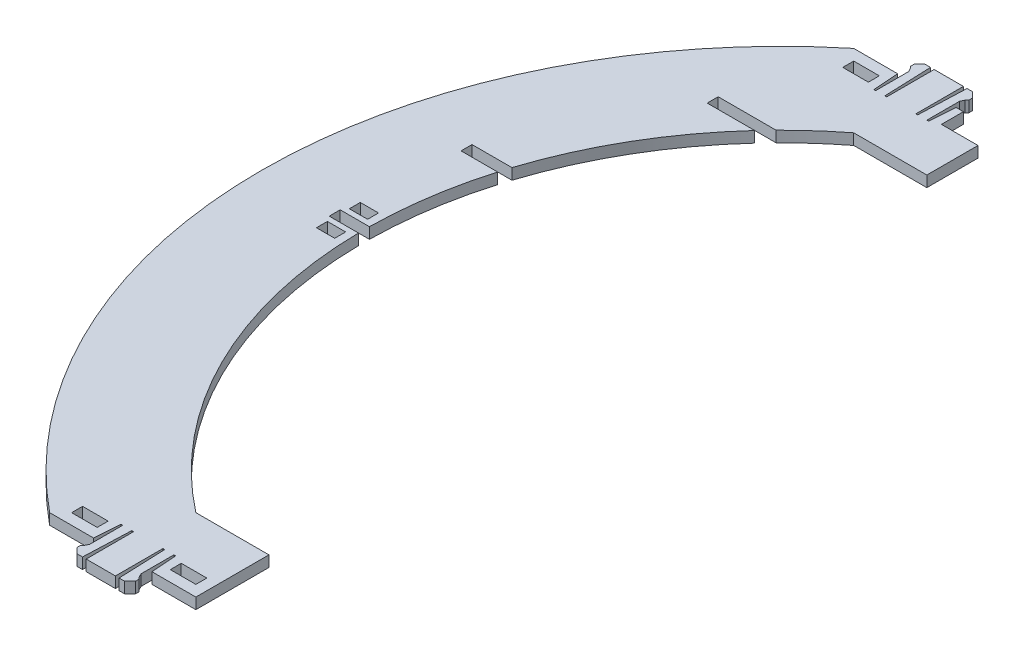
from build123d import *

# Parameters (mm, degrees)
BOSS_EXTRUDE2_DEPTH      = 3
SKETCH3_W                = 10
SKETCH3_H                = 6
SKETCH3_W_2              = 7
SKETCH3_H_2              = 3
CUT_EXTRUDE1_DEPTH       = 3
CUT_EXTRUDE3_DEPTH       = 1
CUT_EXTRUDE3_DEPTH_BACK  = 3
SKETCH10_W               = 5
SKETCH10_H               = 3
CUT_EXTRUDE4_DEPTH       = 10
CUT_EXTRUDE12_DEPTH      = 1
CUT_EXTRUDE12_DEPTH_BACK = 3
CUT_EXTRUDE13_DEPTH      = 1
CUT_EXTRUDE13_DEPTH_BACK = 3


with BuildPart() as part:
    # Sketch2 → Boss-Extrude2 (new body)
    with BuildSketch(Plane(origin=(0, 0, 0), x_dir=(1, 0, 0), z_dir=(0, 1, 0))):
        with BuildLine():
            Line((-70, 90), (-50, 90))
            Line((-50, 90), (-50, 110))
            Line((-50, 110), (-61.99554496, 110))
            Line((-61.99554496, 110), (-62.49554496, 102.997828908))
            Line((-62.49554496, 102.997828908), (-62.99554496, 102.997828908))
            Line((-62.99554496, 102.997828908), (-62.99554496, 111.997828908))
            Line((-62.99554496, 111.997828908), (-62.49554496, 112.997828908))
            Line((-62.49554496, 112.997828908), (-61.99554496, 113.497828908))
            Line((-61.99554496, 113.497828908), (-61.99554496, 114.497828908))
            Line((-61.99554496, 114.497828908), (-63.49554496, 115.997828908))
            Line((-63.49554496, 115.997828908), (-64.99554496, 115.997828908))
            Line((-64.99554496, 115.997828908), (-65.49554496, 102.997828908))
            Line((-65.49554496, 102.997828908), (-65.99554496, 102.997828908))
            Line((-65.99554496, 102.997828908), (-65.99554496, 115.997828908))
            Line((-65.99554496, 115.997828908), (-73.99554496, 115.997828908))
            Line((-73.99554496, 115.997828908), (-73.99554496, 102.997828908))
            Line((-73.99554496, 102.997828908), (-74.49554496, 102.997828908))
            Line((-74.49554496, 102.997828908), (-74.99554496, 115.997828908))
            Line((-74.99554496, 115.997828908), (-76.49554496, 115.997828908))
            Line((-76.49554496, 115.997828908), (-77.99554496, 114.497828908))
            Line((-77.99554496, 114.497828908), (-77.99554496, 113.497828908))
            Line((-77.99554496, 113.497828908), (-77.49554496, 112.997828908))
            Line((-77.49554496, 112.997828908), (-76.99554496, 111.997828908))
            Line((-76.99554496, 111.997828908), (-76.99554496, 102.997828908))
            Line((-76.99554496, 102.997828908), (-77.49554496, 102.997828908))
            Line((-77.49554496, 102.997828908), (-77.99554496, 110))
            Line((-77.99554496, 110), (-90, 110))
            ThreePointArc((-90, 110), (-142.126704036, 0), (-90, -110))
            Line((-90, -110), (-78.00445504, -110))
            Line((-78.00445504, -110), (-77.50445504, -102.997828908))
            Line((-77.50445504, -102.997828908), (-77.00445504, -102.997828908))
            Line((-77.00445504, -102.997828908), (-77.00445504, -111.997828908))
            Line((-77.00445504, -111.997828908), (-77.50445504, -112.997828908))
            Line((-77.50445504, -112.997828908), (-78.00445504, -113.497828908))
            Line((-78.00445504, -113.497828908), (-78.00445504, -114.497828908))
            Line((-78.00445504, -114.497828908), (-76.50445504, -115.997828908))
            Line((-76.50445504, -115.997828908), (-75.00445504, -115.997828908))
            Line((-75.00445504, -115.997828908), (-74.50445504, -102.997828908))
            Line((-74.50445504, -102.997828908), (-74.00445504, -102.997828908))
            Line((-74.00445504, -102.997828908), (-74.00445504, -115.997828908))
            Line((-74.00445504, -115.997828908), (-66.00445504, -115.997828908))
            Line((-66.00445504, -115.997828908), (-66.00445504, -102.997828908))
            Line((-66.00445504, -102.997828908), (-65.50445504, -102.997828908))
            Line((-65.50445504, -102.997828908), (-65.00445504, -115.997828908))
            Line((-65.00445504, -115.997828908), (-63.50445504, -115.997828908))
            Line((-63.50445504, -115.997828908), (-62.00445504, -114.497828908))
            Line((-62.00445504, -114.497828908), (-62.00445504, -113.497828908))
            Line((-62.00445504, -113.497828908), (-62.50445504, -112.997828908))
            Line((-62.50445504, -112.997828908), (-63.00445504, -111.997828908))
            Line((-63.00445504, -111.997828908), (-63.00445504, -102.997828908))
            Line((-63.00445504, -102.997828908), (-62.50445504, -102.997828908))
            Line((-62.50445504, -102.997828908), (-62.00445504, -110))
            Line((-62.00445504, -110), (-50, -110))
            Line((-50, -110), (-50, -90))
            Line((-50, -90), (-70, -90))
            ThreePointArc((-70, -90), (-114.01754251, 0), (-70, 90))
        make_face()
    extrude(amount=BOSS_EXTRUDE2_DEPTH)

    # Sketch3 → Cut-Extrude1 (cut)
    with BuildSketch(Plane(origin=(0, 3, 0), x_dir=(1, 0, 0), z_dir=(0, 1, 0))):
        with Locations((-55, 107)):
            Rectangle(SKETCH3_W, SKETCH3_H)
        with Locations((-83.5, 105.5)):
            Rectangle(SKETCH3_W_2, SKETCH3_H_2)
        with Locations((-56.491089921, -105.5)):
            Rectangle(SKETCH3_W_2, SKETCH3_H_2)
        with Locations((-83.491089921, -105.5)):
            Rectangle(SKETCH3_W_2, SKETCH3_H_2)
    extrude(amount=-CUT_EXTRUDE1_DEPTH, mode=Mode.SUBTRACT)

    # Sketch8 → Cut-Extrude3 (cut, two sides)
    with BuildSketch(Plane(origin=(0, 3, 0), x_dir=(1, 0, 0), z_dir=(0, 1, 0))) as cut_extrude3_sk:
        Polygon((163.594434528, 1.5), (-114.00767518, 1.5), (-122.00767518, 1.5), (-122.00767518, -1.5), (-114.00767518, -1.5), (163.594434528, -1.5), (718.798653945, -1.5), (718.798653945, 1.5), align=None)
    extrude(amount=CUT_EXTRUDE3_DEPTH, mode=Mode.SUBTRACT)
    extrude(cut_extrude3_sk.sketch, amount=-CUT_EXTRUDE3_DEPTH_BACK, mode=Mode.SUBTRACT)

    # Sketch10 → Cut-Extrude4 (cut)
    with BuildSketch(Plane(origin=(0, 3, 0), x_dir=(1, 0, 0), z_dir=(0, 1, 0))):
        with Locations((-118.50767518, 4.5)):
            Rectangle(SKETCH10_W, SKETCH10_H)
        with Locations((-118.50767518, -4.5)):
            Rectangle(SKETCH10_W, SKETCH10_H)
    extrude(amount=-CUT_EXTRUDE4_DEPTH, mode=Mode.SUBTRACT)

    # Sketch9 → Cut-Extrude12 (cut, two sides)
    with BuildSketch(Plane(origin=(0, 3, 0), x_dir=(1, 0, 0), z_dir=(0, 1, 0))) as cut_extrude12_sk:
        Polygon((339.233941087, 80), (-81.240384046, 80), (-97.089238313, 80), (-97.089238313, 77), (-84.089238313, 77), (336.385086821, 77), (946.188662062, -502.080505639), (949.037516328, -499.080505639), align=None)
    extrude(amount=CUT_EXTRUDE12_DEPTH, mode=Mode.SUBTRACT)
    extrude(cut_extrude12_sk.sketch, amount=-CUT_EXTRUDE12_DEPTH_BACK, mode=Mode.SUBTRACT)

    # Sketch13 → Cut-Extrude13 (cut, two sides)
    with BuildSketch(Plane(origin=(0, 3, 0), x_dir=(1, 0, 0), z_dir=(0, 1, 0))) as cut_extrude13_sk:
        Polygon((225.364323888, 35), (-108.512672071, 35), (-119.434912162, 35), (-119.434912162, 32), (-109.434912162, 32), (224.442083797, 32), (862.717356055, -164.214348471), (863.639596146, -161.214348471), align=None)
    extrude(amount=CUT_EXTRUDE13_DEPTH, mode=Mode.SUBTRACT)
    extrude(cut_extrude13_sk.sketch, amount=-CUT_EXTRUDE13_DEPTH_BACK, mode=Mode.SUBTRACT)


solid = part.part
